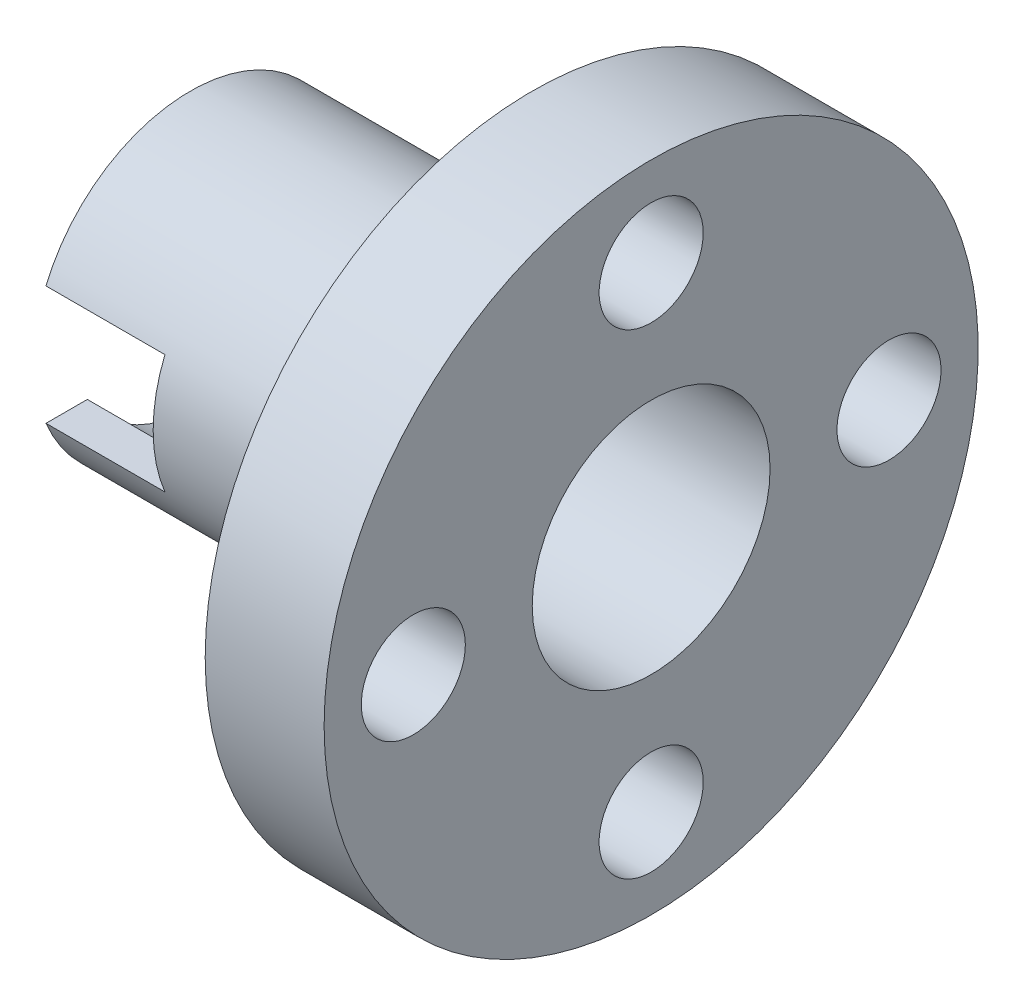
from build123d import *

# Parameters (mm, degrees)
CUT_EXTRUDE1_REACH      = 17.5
SKETCH2_R               = 1.75
SKETCH3_W               = 4
SKETCH3_H               = 4
CUT_EXTRUDE2_DEPTH      = 12
CUT_EXTRUDE2_DEPTH_BACK = 12


with BuildPart() as part:
    # Sketch1 → Revolve1 (revolve)
    with BuildSketch(Plane(origin=(0, 0, 0), x_dir=(1, 0, 0), z_dir=(0, 1, 0))):
        Polygon((-15.5, 4), (-15.5, 5.25), (-4, 5.25), (-4, 11), (0, 11), (0, 4), align=None)
    revolve(axis=Axis((-43.707317073, 0, 0), (1, 0, 0)))

    # Sketch2 → Cut-Extrude1 (cut, up to next)
    with BuildSketch(Plane(origin=(0, 0, 0), x_dir=(0, 0, -1), z_dir=(1, 0, 0)), mode=Mode.PRIVATE) as cut_extrude1_sk1:
        with Locations((0, 8)):
            Circle(SKETCH2_R)
    cut_extrude1_tool1 = extrude(cut_extrude1_sk1.sketch, amount=-CUT_EXTRUDE1_REACH, mode=Mode.PRIVATE) & part.part
    add(cut_extrude1_tool1.solids().sort_by_distance((0, 8, 0))[0], mode=Mode.SUBTRACT)
    # Sketch2 → Cut-Extrude1 (cut, up to next)
    with BuildSketch(Plane(origin=(0, 0, 0), x_dir=(0, 0, -1), z_dir=(1, 0, 0)), mode=Mode.PRIVATE) as cut_extrude1_sk2:
        with Locations((8, 0)):
            Circle(SKETCH2_R)
    cut_extrude1_tool2 = extrude(cut_extrude1_sk2.sketch, amount=-CUT_EXTRUDE1_REACH, mode=Mode.PRIVATE) & part.part
    add(cut_extrude1_tool2.solids().sort_by_distance((0, 0, -8))[0], mode=Mode.SUBTRACT)
    # Sketch2 → Cut-Extrude1 (cut, up to next)
    with BuildSketch(Plane(origin=(0, 0, 0), x_dir=(0, 0, -1), z_dir=(1, 0, 0)), mode=Mode.PRIVATE) as cut_extrude1_sk3:
        with Locations((0, -8)):
            Circle(SKETCH2_R)
    cut_extrude1_tool3 = extrude(cut_extrude1_sk3.sketch, amount=-CUT_EXTRUDE1_REACH, mode=Mode.PRIVATE) & part.part
    add(cut_extrude1_tool3.solids().sort_by_distance((0, -8, 0))[0], mode=Mode.SUBTRACT)
    # Sketch2 → Cut-Extrude1 (cut, up to next)
    with BuildSketch(Plane(origin=(0, 0, 0), x_dir=(0, 0, -1), z_dir=(1, 0, 0)), mode=Mode.PRIVATE) as cut_extrude1_sk4:
        with Locations((-8, 0)):
            Circle(SKETCH2_R)
    cut_extrude1_tool4 = extrude(cut_extrude1_sk4.sketch, amount=-CUT_EXTRUDE1_REACH, mode=Mode.PRIVATE) & part.part
    add(cut_extrude1_tool4.solids().sort_by_distance((0, 0, 8))[0], mode=Mode.SUBTRACT)

    # Sketch3 → Cut-Extrude2 (cut, two sides)
    with BuildSketch(Plane.XY) as cut_extrude2_sk:
        with Locations((-13.5, 0)):
            Rectangle(SKETCH3_W, SKETCH3_H)
    extrude(amount=CUT_EXTRUDE2_DEPTH, mode=Mode.SUBTRACT)
    extrude(cut_extrude2_sk.sketch, amount=-CUT_EXTRUDE2_DEPTH_BACK, mode=Mode.SUBTRACT)


solid = part.part
